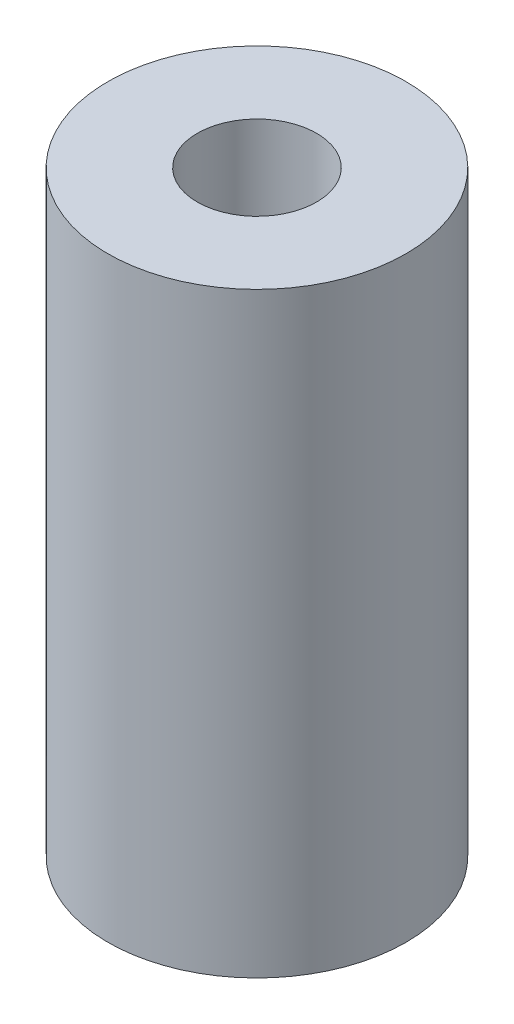
from build123d import *

# Parameters (mm, degrees)
SKETCH1_R           = 2.5
SKETCH1_R_2         = 1
EXTRUDE_THIN1_DEPTH = 10


with BuildPart() as part:
    # Sketch1 → Extrude-Thin1 (new body)
    with BuildSketch(Plane(origin=(0, 0, 0), x_dir=(1, 0, 0), z_dir=(0, 1, 0))):
        Circle(SKETCH1_R)
        Circle(SKETCH1_R_2, mode=Mode.SUBTRACT)
    extrude(amount=EXTRUDE_THIN1_DEPTH)


solid = part.part
